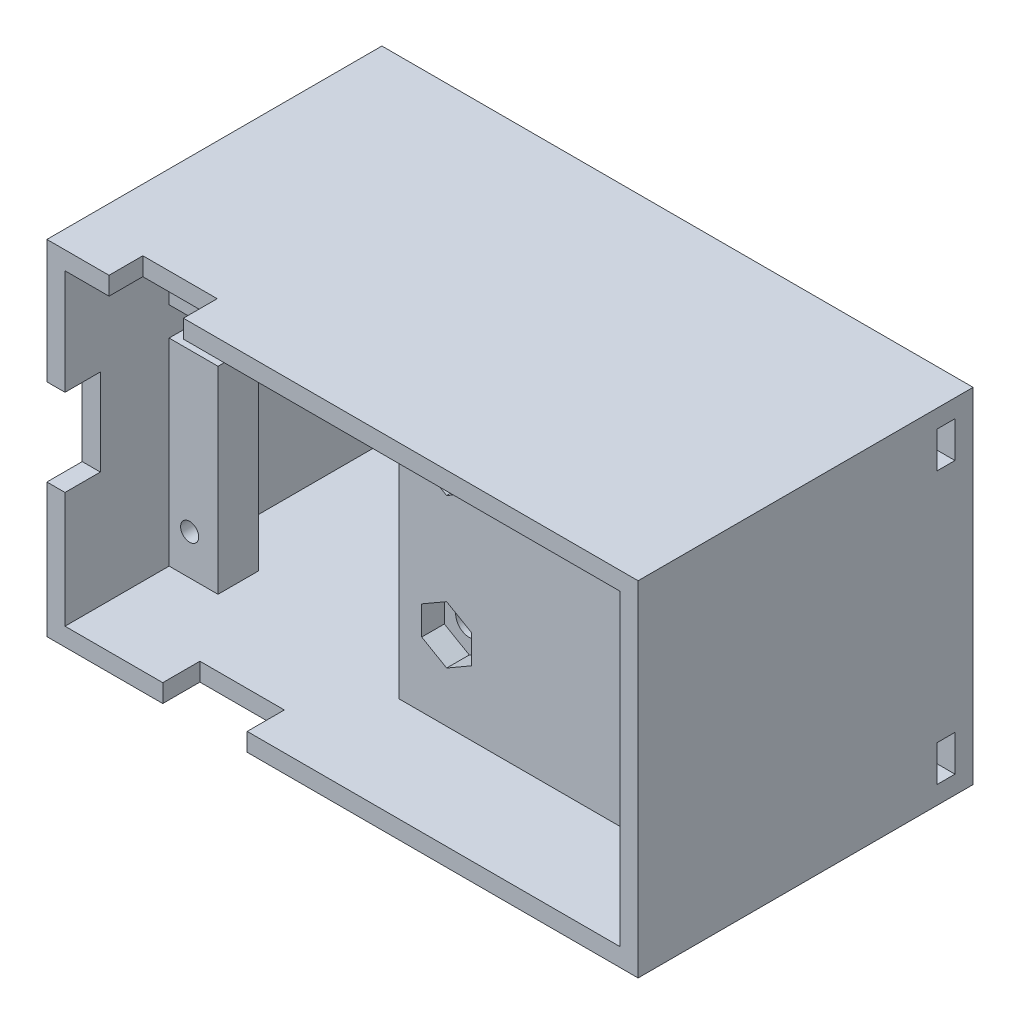
from build123d import *

# Parameters (mm, degrees)
SKETCH_2_W           = 65.2997206
SKETCH_2_H           = 38
SKETCH_2_R           = 1.00000254
SKETCH_2_R_2         = 0.922218434
SKETCH_2_R_3         = 1.5
EXTRUDE_2_DEPTH      = 4.5
SKETCH_3_R           = 1.5
CUT_EXTRUDE_2_DEPTH  = 2.5
SKETCH_5_W           = 65.2997206
SKETCH_5_H           = 38
SKETCH_5_W_2         = 61.2997206
SKETCH_5_H_2         = 34
EXTRUDE_3_DEPTH      = 21
EXTRUDE_3_DEPTH_BACK = 16
SKETCH_7_W           = 8.214112973
SKETCH_7_H           = 3.795011114
CUT_EXTRUDE_4_DEPTH  = 3
SKETCH_8_W           = 4
SKETCH_8_H           = 9.575559499
CUT_EXTRUDE_5_DEPTH  = 3
SKETCH_9_W           = 9.326303795
SKETCH_9_H           = 4.202278939
CUT_EXTRUDE_6_DEPTH  = 3
CUT_EXTRUDE_7_DEPTH  = 10
SKETCH_15_R          = 1.75
CUT_EXTRUDE_8_DEPTH  = 1.5
SKETCH_18_W          = 61.2997206
SKETCH_18_H          = 35
CUT_EXTRUDE_9_DEPTH  = 2
SKETCH_19_W          = 2
SKETCH_19_H          = 4
CUT_EXTRUDE_10_DEPTH = 2
SKETCH_20_W          = 2
SKETCH_20_H          = 8
CUT_EXTRUDE_11_DEPTH = 1.2
SKETCH_21_W          = 2
SKETCH_21_H          = 8
CUT_EXTRUDE_12_DEPTH = 2


with BuildPart() as part:
    # 草图2 → 凸台-拉伸2 (new body)
    with BuildSketch(Plane(origin=(0, 0, -6), x_dir=(-1, 0, 0), z_dir=(0, 0, -1))):
        with Locations((29.273558547, -24.066548133)):
            Rectangle(SKETCH_2_W, SKETCH_2_H)
        with Locations((1.016002032, -11.24978156)):
            Circle(SKETCH_2_R, mode=Mode.SUBTRACT)
        with Locations((0.889001778, -36.83007366)):
            Circle(SKETCH_2_R, mode=Mode.SUBTRACT)
        with Locations((57.658115316, -36.64983236)):
            Circle(SKETCH_2_R, mode=Mode.SUBTRACT)
        with Locations((57.658115316, -11.24978156)):
            Circle(SKETCH_2_R_2, mode=Mode.SUBTRACT)
        with Locations((29.273558547, -32.316548133)):
            Circle(SKETCH_2_R_3, mode=Mode.SUBTRACT)
        with BuildLine():
            Line((27.785407033, -15.816548133), (27.785407033, -13.183619987))
            ThreePointArc((27.785407033, -13.183619987), (29.273558547, -11.695468472), (30.761710061, -13.183619987))
            Line((30.761710061, -13.183619987), (30.761710061, -15.816548133))
            ThreePointArc((30.761710061, -15.816548133), (29.273558547, -17.304699647), (27.785407033, -15.816548133))
        make_face(mode=Mode.SUBTRACT)
    extrude(amount=EXTRUDE_2_DEPTH)

    # 草图3 → 切除-拉伸2 (cut)
    with BuildSketch(Plane(origin=(0, 0, -6), x_dir=(-1, 0, 0), z_dir=(0, 0, -1))):
        Polygon((29.273558547, -18.991974614), (32.023558547, -17.404261373), (32.023558547, -14.920341582), (32.023558547, -14.228834893), (32.023558547, -11.744915102), (29.273558547, -10.157201862), (26.523558547, -11.744915102), (26.523558547, -14.228834893), (26.523558547, -14.920341582), (26.523558547, -17.404261373), align=None)
        with BuildLine():
            ThreePointArc((30.761710061, -15.816548133), (29.273558547, -17.304699647), (27.785407033, -15.816548133))
            Line((27.785407033, -15.816548133), (27.785407033, -13.183619987))
            ThreePointArc((27.785407033, -13.183619987), (29.273558547, -11.695468472), (30.761710061, -13.183619987))
            Line((30.761710061, -13.183619987), (30.761710061, -15.816548133))
        make_face(mode=Mode.SUBTRACT)
        Polygon((26.523558547, -30.728834893), (26.523558547, -33.904261373), (29.273558547, -35.491974614), (32.023558547, -33.904261373), (32.023558547, -30.728834893), (29.273558547, -29.141121653), align=None)
        with Locations((29.273558547, -32.316548133)):
            Circle(SKETCH_3_R, mode=Mode.SUBTRACT)
    extrude(amount=CUT_EXTRUDE_2_DEPTH, mode=Mode.SUBTRACT)

    # 草图5 → 凸台-拉伸3 (add, two sides)
    with BuildSketch(Plane(origin=(0, 0, -10.5), x_dir=(-1, 0, 0), z_dir=(0, 0, -1))) as extrude_3_sk:
        with Locations((29.273558547, -24.066548133)):
            Rectangle(SKETCH_5_W, SKETCH_5_H)
        with Locations((29.273558547, -24.066548133)):
            Rectangle(SKETCH_5_W_2, SKETCH_5_H_2, mode=Mode.SUBTRACT)
    extrude(amount=EXTRUDE_3_DEPTH)
    extrude(extrude_3_sk.sketch, amount=-EXTRUDE_3_DEPTH_BACK)

    # 草图7 → 切除-拉伸4 (cut)
    with BuildSketch(Plane(origin=(0, -5.066548133, 0), x_dir=(1, 0, 0), z_dir=(0, 1, 0))):
        with Locations((-50.955145133, -3.662545243)):
            Rectangle(SKETCH_7_W, SKETCH_7_H)
    extrude(amount=-CUT_EXTRUDE_4_DEPTH, mode=Mode.SUBTRACT)

    # 草图8 → 切除-拉伸5 (cut)
    with BuildSketch(Plane.ZY.offset(61.923418847)):
        with Locations((3.6000508, -23.483057223)):
            Rectangle(SKETCH_8_W, SKETCH_8_H)
    extrude(amount=-CUT_EXTRUDE_5_DEPTH, mode=Mode.SUBTRACT)

    # 草图9 → 切除-拉伸6 (cut)
    with BuildSketch(Plane.XZ.offset(43.066548133)):
        with Locations((-44.464129124, 3.49891133)):
            Rectangle(SKETCH_9_W, SKETCH_9_H)
    extrude(amount=-CUT_EXTRUDE_6_DEPTH, mode=Mode.SUBTRACT)

    # 草图13 → 切除-拉伸7 (cut)
    with BuildSketch(Plane.XY.offset(-6)):
        Polygon((-59.923418847, -16.066514367), (-59.923418847, -19.252115931), (-54.525349934, -19.252115931), (-54.525349934, -41.066548133), (-34.525349934, -41.066548133), (-34.525349934, -7.066548133), (-54.525349934, -7.066548133), (-54.525349934, -12.880912803), (-54.525349934, -16.066514367), align=None)
    extrude(amount=-CUT_EXTRUDE_7_DEPTH, mode=Mode.SUBTRACT)

    # 草图15 → 切除-拉伸8 (cut)
    with BuildSketch(Plane(origin=(0, 0, -10.5), x_dir=(-1, 0, 0), z_dir=(0, 0, -1))):
        with Locations((1.016002032, -11.24978156)):
            Circle(SKETCH_15_R)
        with Locations((57.658115316, -11.24978156)):
            Circle(SKETCH_15_R)
        with Locations((0.889001778, -36.83007366)):
            Circle(SKETCH_15_R)
        with Locations((57.658115316, -36.64983236)):
            Circle(SKETCH_15_R)
    extrude(amount=-CUT_EXTRUDE_8_DEPTH, mode=Mode.SUBTRACT)

    # 草图18 → 切除-拉伸9 (cut)
    with BuildSketch(Plane(origin=(0, 0, -31.5), x_dir=(-1, 0, 0), z_dir=(0, 0, -1))):
        with Locations((29.273558547, -24.066548133)):
            Rectangle(SKETCH_18_W, SKETCH_18_H)
    extrude(amount=-CUT_EXTRUDE_9_DEPTH, mode=Mode.SUBTRACT)

    # 草图19 → 切除-拉伸10 (cut)
    with BuildSketch(Plane.ZY.offset(-1.376301753)):
        with Locations((-28.5, -9.066548133)):
            Rectangle(SKETCH_19_W, SKETCH_19_H)
        with Locations((-28.5, -39.066548133)):
            Rectangle(SKETCH_19_W, SKETCH_19_H)
    extrude(amount=-CUT_EXTRUDE_10_DEPTH, mode=Mode.SUBTRACT)

    # 草图20 → 切除-拉伸11 (cut)
    with BuildSketch(Plane(origin=(0, 0, -31.5), x_dir=(-1, 0, 0), z_dir=(0, 0, -1))):
        with Locations((60.923418847, -24.066548133)):
            Rectangle(SKETCH_20_W, SKETCH_20_H)
    extrude(amount=-CUT_EXTRUDE_11_DEPTH, mode=Mode.SUBTRACT)

    # 草图21 → 切除-拉伸12 (cut)
    with BuildSketch(Plane.ZY.offset(61.923418847)):
        with Locations((-27.7, -24.066548133)):
            Rectangle(SKETCH_21_W, SKETCH_21_H)
    extrude(amount=-CUT_EXTRUDE_12_DEPTH, mode=Mode.SUBTRACT)


solid = part.part
